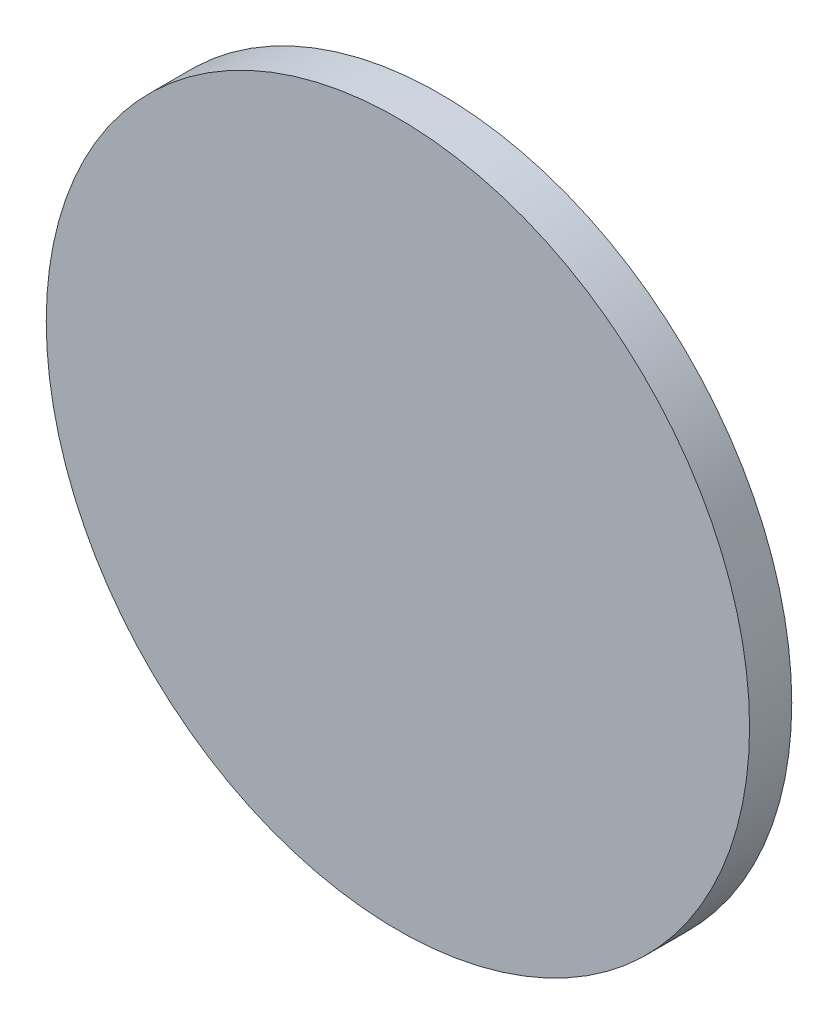
from build123d import *

# Parameters (mm, degrees)
SKETCH_1_R      = 25
EXTRUDE_1_DEPTH = 3


with BuildPart() as part:
    # 草图1 → 凸台-拉伸1 (new body)
    with BuildSketch(Plane.XY):
        Circle(SKETCH_1_R)
    extrude(amount=EXTRUDE_1_DEPTH)


solid = part.part
